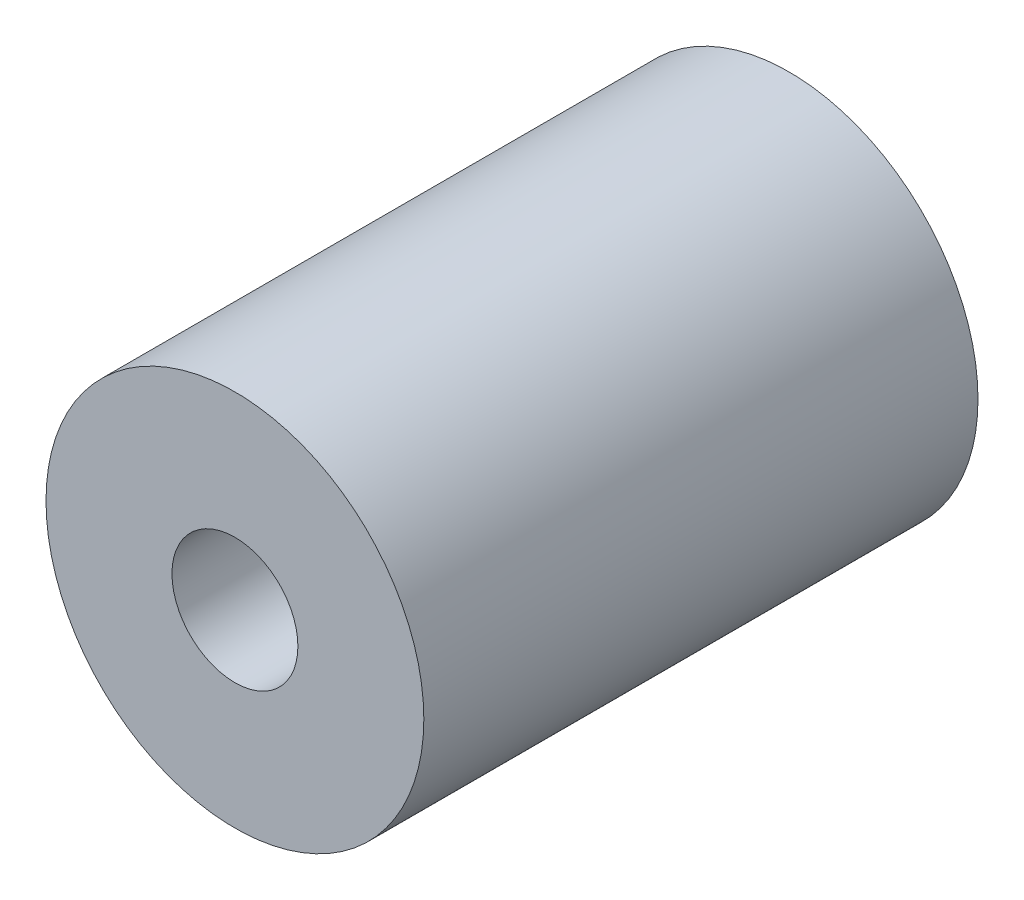
from build123d import *

# Parameters (mm, degrees)
SKETCH1_R           = 9.525
SKETCH1_R_2         = 3.175
BOSS_EXTRUDE1_DEPTH = 27.94
SKETCH2_R           = 4.7625
SKETCH2_R_2         = 3.175
CUT_EXTRUDE1_DEPTH  = 6.5024


with BuildPart() as part:
    # Sketch1 → Boss-Extrude1 (new body)
    with BuildSketch(Plane.XY):
        Circle(SKETCH1_R)
        Circle(SKETCH1_R_2, mode=Mode.SUBTRACT)
    extrude(amount=BOSS_EXTRUDE1_DEPTH)

    # Sketch2 → Cut-Extrude1 (cut)
    with BuildSketch(Plane(origin=(0, 0, 0), x_dir=(-1, 0, 0), z_dir=(0, 0, -1))):
        Circle(SKETCH2_R)
        Circle(SKETCH2_R_2, mode=Mode.SUBTRACT)
    extrude(amount=-CUT_EXTRUDE1_DEPTH, mode=Mode.SUBTRACT)


solid = part.part
